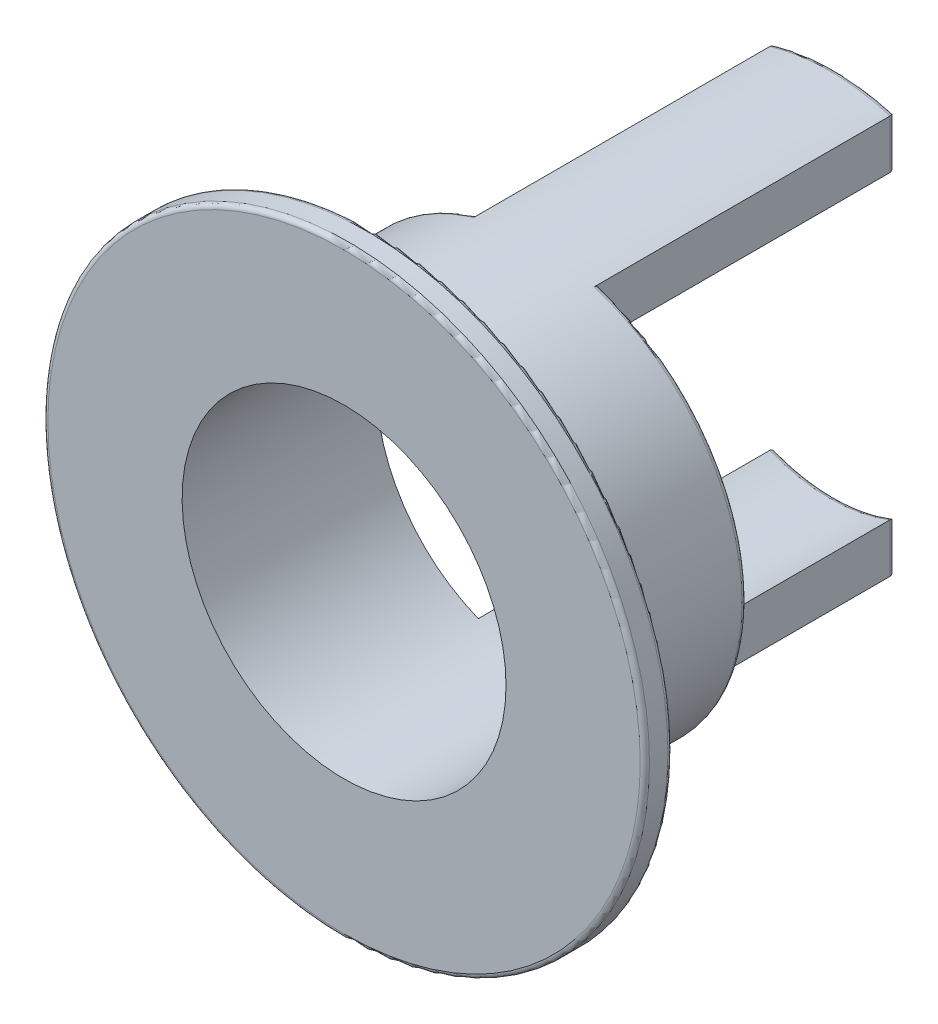
from build123d import *

# Parameters (mm, degrees)
SKETCH_1_R          = 3.25
SKETCH_1_R_2        = 2.25
SKETCH_1_R_3        = 1.75
EXTRUDE_1_DEPTH     = 0.3
SKETCH_1_4_R        = 2.25
SKETCH_1_4_R_2      = 1.75
EXTRUDE_2_DEPTH     = 5
CUT_EXTRUDE_1_DEPTH = 3.2
FILLET_1_R          = 0.05


with BuildPart() as part:
    # Sketch 1 → Extrude 1 (new body)
    with BuildSketch(Plane.XY):
        Circle(SKETCH_1_R)
        Circle(SKETCH_1_R_2, mode=Mode.SUBTRACT)
        Circle(SKETCH_1_R_2)
        Circle(SKETCH_1_R_3, mode=Mode.SUBTRACT)
    extrude(amount=EXTRUDE_1_DEPTH)

    # Sketch 1_4 → Extrude 2 (add)
    with BuildSketch(Plane.XY):
        Circle(SKETCH_1_4_R)
        Circle(SKETCH_1_4_R_2, mode=Mode.SUBTRACT)
    extrude(amount=-EXTRUDE_2_DEPTH)

    # Sketch 2 → Cut-Extrude 1 (cut)
    with BuildSketch(Plane(origin=(0, 0, -5), x_dir=(-1, 0, 0), z_dir=(0, 0, -1))):
        with BuildLine():
            ThreePointArc((-0.65, 2.154065923), (-2.25, 0), (-0.65, -2.154065923))
            Line((-0.65, -2.154065923), (-0.65, -1.624807681))
            ThreePointArc((-0.65, -1.624807681), (-1.75, 0), (-0.65, 1.624807681))
            Line((-0.65, 1.624807681), (-0.65, 2.154065923))
        make_face()
        with BuildLine():
            Line((0.65, -1.624807681), (0.65, -2.154065923))
            ThreePointArc((0.65, -2.154065923), (1.806239187, -1.341640786), (2.25, 0))
            ThreePointArc((2.25, 0), (1.806239187, 1.341640786), (0.65, 2.154065923))
            Line((0.65, 2.154065923), (0.65, 1.624807681))
            ThreePointArc((0.65, 1.624807681), (1.449137675, 0.981070844), (1.75, 0))
            ThreePointArc((1.75, 0), (1.449137675, -0.981070844), (0.65, -1.624807681))
        make_face()
    extrude(amount=-CUT_EXTRUDE_1_DEPTH, mode=Mode.SUBTRACT)

    # Fillet 1
    fillet_1_edges = [part.edges().sort_by_distance(p)[0] for p in [
        (1.806239187, 1.341640786, -1.8),
        (0.65, -1.889436802, -5),
        (0.65, 1.889436802, -5),
        (0, -2.25, -5),
        (0, -1.75, -5),
        (-0.65, -1.889436802, -5),
        (-0.65, 1.889436802, -5),
        (-2.25, 0, -1.8),
        (-3.25, 0, 0),
        (-3.25, 0, 0.3),
        (0, 2.25, -5),
        (0, 1.75, -5),
    ]]
    fillet(fillet_1_edges, radius=FILLET_1_R)


solid = part.part
